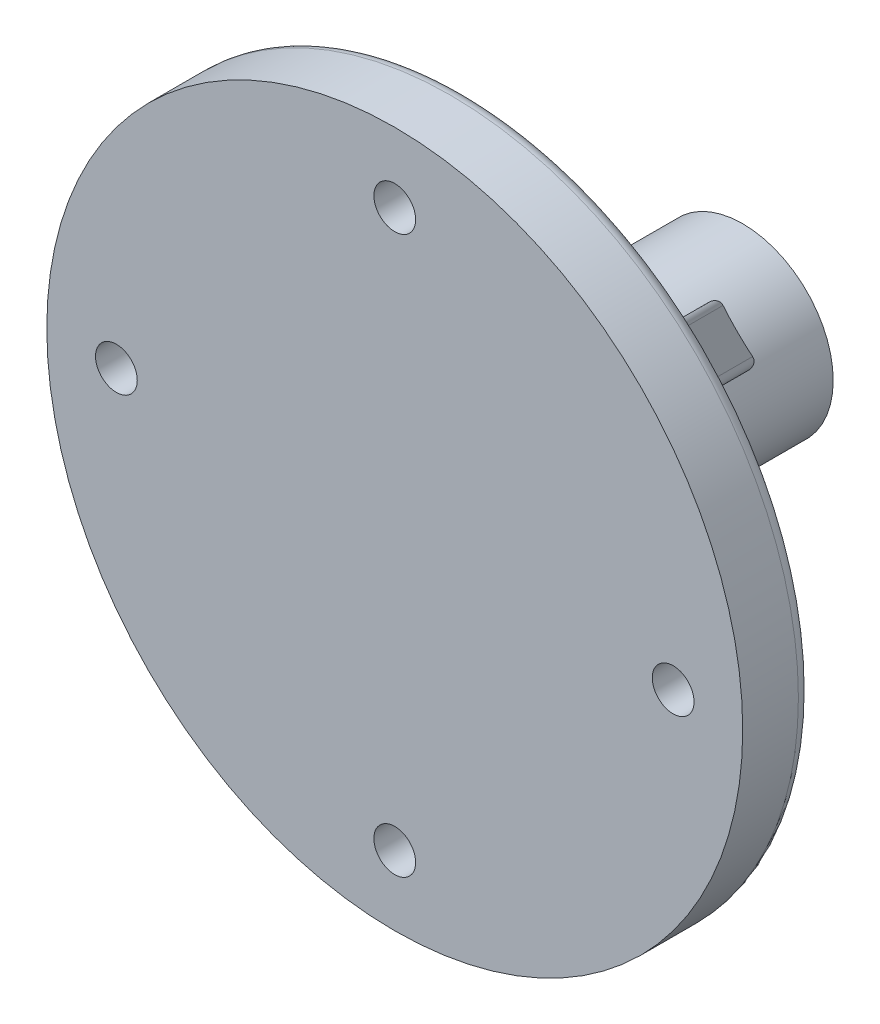
from build123d import *

# Parameters (mm, degrees)
SKETCH1_R           = 6.5
BOSS_EXTRUDE1_DEPTH = 20
SKETCH4_R           = 2.6
CUT_EXTRUDE1_DEPTH  = 15.5
FILLET1_R           = 1
SKETCH5_R           = 25
BOSS_EXTRUDE2_DEPTH = 5
CUT_EXTRUDE2_REACH  = 42.62
SKETCH6_R           = 1.5
FILLET2_R           = 7
RIB10_REACH         = 45.301
SKETCH12_WALL_W     = 109.815743814
SKETCH12_WALL_H     = 4
CIRPATTERN1_COUNT   = 4
FILLET3_R           = 1
FILLET4_R           = 0.5
SKETCH13_R          = 3
CUT_EXTRUDE3_DEPTH  = 1


with BuildPart() as part:
    # Sketch1 → Boss-Extrude1 (new body)
    with BuildSketch(Plane.XY):
        Circle(SKETCH1_R)
    extrude(amount=BOSS_EXTRUDE1_DEPTH)

    # Sketch4 → Cut-Extrude1 (cut)
    with BuildSketch(Plane(origin=(0, 0, 0), x_dir=(-1, 0, 0), z_dir=(0, 0, -1))):
        Circle(SKETCH4_R)
    extrude(amount=-CUT_EXTRUDE1_DEPTH, mode=Mode.SUBTRACT)

    # Fillet1
    fillet1_edges = [part.edges().sort_by_distance(p)[0] for p in [
        (2.6, 0, 15.5),
    ]]
    fillet(fillet1_edges, radius=FILLET1_R)

    # Sketch5 → Boss-Extrude2 (add)
    with BuildSketch(Plane.XY.offset(20)):
        Circle(SKETCH5_R)
    extrude(amount=BOSS_EXTRUDE2_DEPTH)

    # Sketch6 → Cut-Extrude2 (cut, up to next)
    with BuildSketch(Plane(origin=(0, 0, 20), x_dir=(-1, 0, 0), z_dir=(0, 0, -1)), mode=Mode.PRIVATE) as cut_extrude2_sk1:
        with Locations((0, 20)):
            Circle(SKETCH6_R)
    cut_extrude2_tool1 = extrude(cut_extrude2_sk1.sketch, amount=-CUT_EXTRUDE2_REACH, mode=Mode.PRIVATE) & part.part
    # Sketch6 → Cut-Extrude2 (cut, up to next)
    with BuildSketch(Plane(origin=(0, 0, 20), x_dir=(-1, 0, 0), z_dir=(0, 0, -1)), mode=Mode.PRIVATE) as cut_extrude2_sk2:
        with Locations((0, -20)):
            Circle(SKETCH6_R)
    cut_extrude2_tool2 = extrude(cut_extrude2_sk2.sketch, amount=-CUT_EXTRUDE2_REACH, mode=Mode.PRIVATE) & part.part
    # Sketch6 → Cut-Extrude2 (cut, up to next)
    with BuildSketch(Plane(origin=(0, 0, 20), x_dir=(-1, 0, 0), z_dir=(0, 0, -1)), mode=Mode.PRIVATE) as cut_extrude2_sk3:
        with Locations((-20, 0)):
            Circle(SKETCH6_R)
    cut_extrude2_tool3 = extrude(cut_extrude2_sk3.sketch, amount=-CUT_EXTRUDE2_REACH, mode=Mode.PRIVATE) & part.part
    # Sketch6 → Cut-Extrude2 (cut, up to next)
    with BuildSketch(Plane(origin=(0, 0, 20), x_dir=(-1, 0, 0), z_dir=(0, 0, -1)), mode=Mode.PRIVATE) as cut_extrude2_sk4:
        with Locations((20, 0)):
            Circle(SKETCH6_R)
    cut_extrude2_tool4 = extrude(cut_extrude2_sk4.sketch, amount=-CUT_EXTRUDE2_REACH, mode=Mode.PRIVATE) & part.part
    add(cut_extrude2_tool1.solids().sort_by_distance((0, 20, 20))[0], mode=Mode.SUBTRACT)
    add(cut_extrude2_tool2.solids().sort_by_distance((0, -20, 20))[0], mode=Mode.SUBTRACT)
    add(cut_extrude2_tool3.solids().sort_by_distance((20, 0, 20))[0], mode=Mode.SUBTRACT)
    add(cut_extrude2_tool4.solids().sort_by_distance((-20, 0, 20))[0], mode=Mode.SUBTRACT)

    # Fillet2
    fillet2_edges = [part.edges().sort_by_distance(p)[0] for p in [
        (-6.5, 0, 20),
    ]]
    fillet(fillet2_edges, radius=FILLET2_R)

    # Sketch12 wall → Rib10 (add, up to next)
    with BuildSketch(Plane(origin=(9.899494937, 9.899494937, 12.5), x_dir=(0.500000000005, 0.500000000005, 0.70710678118), z_dir=(0.499999999995, 0.499999999995, -0.707106781193)), mode=Mode.PRIVATE) as rib10_sk1:
        Rectangle(SKETCH12_WALL_W, SKETCH12_WALL_H)
    rib10_tool1 = extrude(rib10_sk1.sketch, amount=-RIB10_REACH, mode=Mode.PRIVATE) - part.part
    rib10 = rib10_tool1.solids().sort_by_distance((9.899494937, 9.899494937, 12.5))[0]
    add(rib10)

    # CirPattern1: Rib10 ×4 about axis
    cirpattern1_axis = Axis((0, 0, 0), (0, 0, 1))
    for i in range(1, CIRPATTERN1_COUNT):
        add(rib10.rotate(cirpattern1_axis, i * 360 / CIRPATTERN1_COUNT))

    # Fillet3
    fillet3_edges = [part.edges().sort_by_distance(p)[0] for p in [
        (-25, 0, 20),
    ]]
    fillet(fillet3_edges, radius=FILLET3_R)

    # Fillet4
    fillet4_edges = [part.edges().sort_by_distance(p)[0] for p in [
        (8.373791296, -11.202218421, 12.342329219),
        (11.202218421, -8.373791296, 12.342329219),
        (-8.373791296, -11.202218421, 12.342329219),
        (-11.202218421, -8.373791296, 12.342329219),
        (11.202218421, 8.373791296, 12.342329219),
        (8.373791296, 11.202218421, 12.342329219),
        (-11.202218421, 8.373791296, 12.342329219),
        (-8.373791296, 11.202218421, 12.342329219),
    ]]
    fillet(fillet4_edges, radius=FILLET4_R)

    # Sketch13 → Cut-Extrude3 (cut)
    with BuildSketch(Plane(origin=(0, 0, 20), x_dir=(-1, 0, 0), z_dir=(0, 0, -1))):
        with Locations((-20, 0)):
            Circle(SKETCH13_R)
        with Locations((0, 20)):
            Circle(SKETCH13_R)
        with Locations((20, 0)):
            Circle(SKETCH13_R)
        with Locations((0, -20)):
            Circle(SKETCH13_R)
    extrude(amount=-CUT_EXTRUDE3_DEPTH, mode=Mode.SUBTRACT)


solid = part.part
